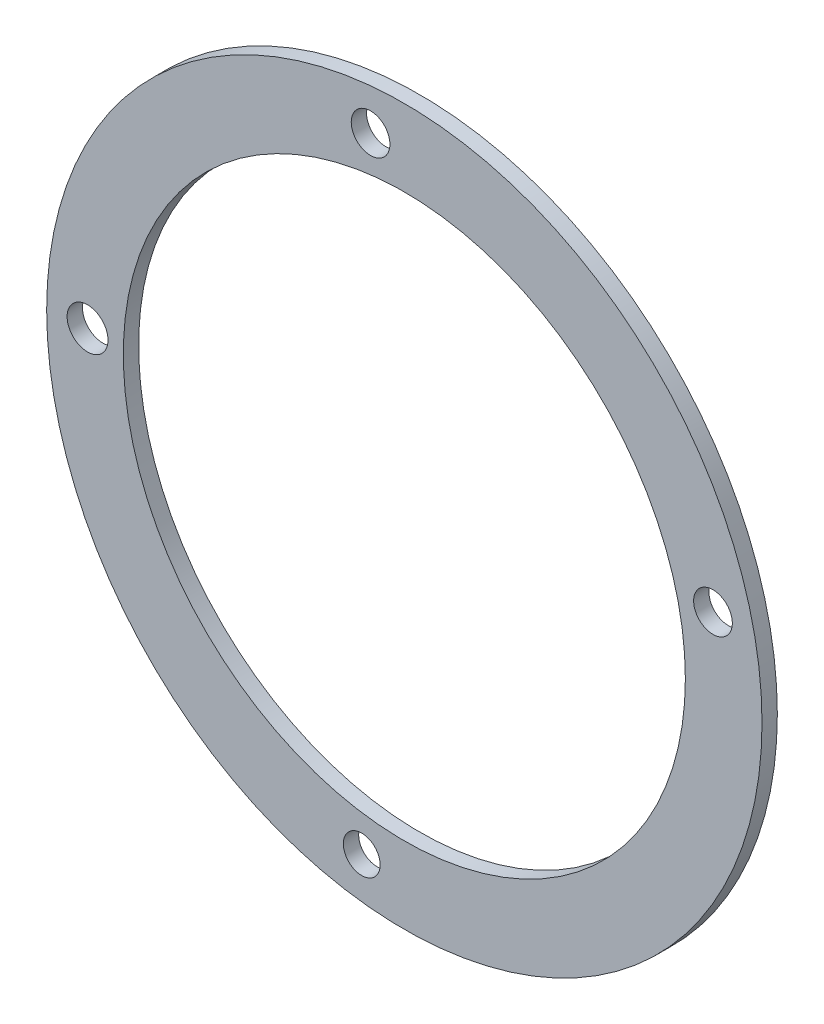
from build123d import *

# Parameters (mm, degrees)
SKETCH_1_R          = 70
SKETCH_1_R_2        = 55
EXTRUDE_1_DEPTH     = 3
SKETCH_2_R          = 4
SKETCH_2_R_2        = 3.785558093
SKETCH_2_R_3        = 3.6
CUT_EXTRUDE_1_DEPTH = 3


with BuildPart() as part:
    # 草图1 → 凸台-拉伸1 (new body)
    with BuildSketch(Plane.XY):
        Circle(SKETCH_1_R)
        Circle(SKETCH_1_R_2, mode=Mode.SUBTRACT)
    extrude(amount=EXTRUDE_1_DEPTH)

    # 草图2 → 切除-拉伸1 (cut)
    with BuildSketch(Plane(origin=(0, 0, 0), x_dir=(-1, 0, 0), z_dir=(0, 0, -1))):
        with Locations((61.993866089, 0.872105092)):
            Circle(SKETCH_2_R)
        with Locations((6.606788351, 61.646981659)):
            Circle(SKETCH_2_R_2)
        with Locations((-60.40114542, 13.989339942)):
            Circle(SKETCH_2_R_2)
        with Locations((8.338281279, -61.436740354)):
            Circle(SKETCH_2_R_3)
    extrude(amount=-CUT_EXTRUDE_1_DEPTH, mode=Mode.SUBTRACT)


solid = part.part
